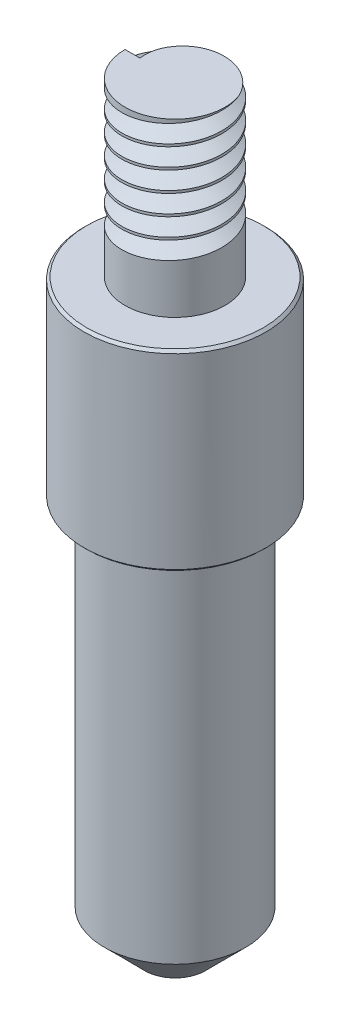
from build123d import *

# Parameters (mm, degrees)
CHAMFER1_SIZE = 0.25
CHAMFER2_SIZE = 0.25


with BuildPart() as part:
    # Sketch1 → Revolve1 (revolve)
    with BuildSketch(Plane.XY, mode=Mode.PRIVATE) as revolve1_sk:
        Polygon((9, 39), (9, 58), (4.95, 58), (4.95, 75), (0, 75), (0, 0), (3, 0), (7, 4), (7, 39), align=None)
    revolve(revolve1_sk.sketch.rotate(Axis((0, 0, 0), (0, 1, 0)), 90), axis=Axis((0, 0, 0), (0, 1, 0)))  # turned: the seam where the file's is

    # Chamfer1
    chamfer1_edges = [part.edges().sort_by_distance(p)[0] for p in [
        (0, 58, 9),
    ]]
    chamfer(chamfer1_edges, length=CHAMFER1_SIZE)

    # Chamfer2
    chamfer2_edges = [part.edges().sort_by_distance(p)[0] for p in [
        (0, 39, 9),
    ]]
    chamfer(chamfer2_edges, length=CHAMFER2_SIZE)

    # Cut-Sweep2: sweep along a curve in space
    with BuildLine() as cut_sweep2_path:
        add(Edge.make_bspline(
            [(-5, 75, 0), (-5, 74.958599466, -0.650318071), (-4.739659358, 74.874876487, -1.965130442), (-3.627578223, 74.750033095, -3.627069319), (-1.963231187, 74.624991132, -4.739795718), (0, 74.500002376, -5.130133783), (1.963231187, 74.374999363, -4.739669148), (3.627578223, 74.250000171, -3.627575599), (4.739659358, 74.124999954, -1.96323189), (5.130170321, 74.000000012, 1.88e-07), (4.739659358, 73.874999997, 1.963231137), (3.627578223, 73.750000001, 3.627578236), (1.963231187, 73.625, 4.739659354), (0, 73.5, 5.130170322), (-1.963231187, 73.375, 4.739659358), (-3.627578223, 73.25, 3.627578223), (-4.739659358, 73.125, 1.963231187), (-5.130170321, 73, 0), (-4.739659358, 72.875, -1.963231187), (-3.627578223, 72.75, -3.627578223), (-1.963231187, 72.625, -4.739659358), (0, 72.5, -5.130170321), (1.963231187, 72.375, -4.739659358), (3.627578223, 72.25, -3.627578223), (4.739659358, 72.125, -1.963231187), (5.130170321, 72, 0), (4.739659358, 71.875, 1.963231187), (3.627578223, 71.75, 3.627578223), (1.963231187, 71.625, 4.739659358), (0, 71.5, 5.130170321), (-1.963231187, 71.375, 4.739659358), (-3.627578223, 71.25, 3.627578223), (-4.739659358, 71.125, 1.963231187), (-5.130170321, 71, 0), (-4.739659358, 70.875, -1.963231187), (-3.627578223, 70.75, -3.627578223), (-1.963231187, 70.625, -4.739659358), (0, 70.5, -5.130170321), (1.963231187, 70.375, -4.739659358), (3.627578223, 70.25, -3.627578223), (4.739659358, 70.125, -1.963231187), (5.130170321, 70, 0), (4.739659358, 69.875, 1.963231187), (3.627578223, 69.75, 3.627578223), (1.963231187, 69.625, 4.739659358), (0, 69.5, 5.130170321), (-1.963231187, 69.375, 4.739659358), (-3.627578223, 69.25, 3.627578223), (-4.739659358, 69.125, 1.963231187), (-5.130170321, 69, 0), (-4.739659358, 68.875, -1.963231187), (-3.627578223, 68.75, -3.627578223), (-1.963231187, 68.625, -4.739659358), (0, 68.5, -5.130170321), (1.963231187, 68.375, -4.739659358), (3.627578223, 68.25, -3.627578223), (4.739659358, 68.125, -1.963231187), (5.130170321, 68, 0), (4.739659358, 67.875, 1.963231187), (3.627578223, 67.75, 3.627578223), (1.963231187, 67.625, 4.739659358), (0, 67.5, 5.130170321), (-1.963231187, 67.375, 4.739659358), (-3.627578223, 67.25, 3.627578223), (-4.739659358, 67.125, 1.963231187), (-5.130170321, 67, 0), (-4.739659358, 66.875, -1.963231187), (-3.627578223, 66.75, -3.627578223), (-1.963231187, 66.625, -4.739659358), (0, 66.5, -5.130170321), (1.963231187, 66.375, -4.739659358), (3.627578223, 66.25, -3.627578223), (4.739659358, 66.125, -1.963231187), (5.130170321, 66, 0), (4.739659358, 65.875, 1.963231187), (3.627578223, 65.75, 3.627578223), (1.963231187, 65.625, 4.739659358), (0, 65.5, 5.130170321), (-1.963231187, 65.375, 4.739659358), (-3.627578223, 65.25, 3.627578223), (-4.739659358, 65.125, 1.963231187), (-5.130170321, 65, 0), (-4.739659358, 64.875, -1.963231187), (-3.627578223, 64.75, -3.627578223), (-1.963231187, 64.625, -4.739659358), (0, 64.5, -5.130170322), (1.963231187, 64.375, -4.739659354), (3.627578223, 64.249999999, -3.627578236), (4.739659358, 64.125000003, -1.963231137), (5.130170321, 63.999999988, -1.88e-07), (4.739659358, 63.875000046, 1.96323189), (3.627578223, 63.749999829, 3.627575599), (1.963231187, 63.625000637, 4.739669148), (0, 63.499997624, 5.130133783), (-1.963231187, 63.375008868, 4.739795718), (-3.627578223, 63.249966905, 3.627069319), (-4.739659358, 63.125123513, 1.965130442), (-5, 63.041400534, 0.650318071), (-5, 63, 0)],
            knots=[0, 0, 0, 0, 0.010416667, 0.020833333, 0.03125, 0.041666667, 0.052083333, 0.0625, 0.072916667, 0.083333333, 0.09375, 0.104166667, 0.114583333, 0.125, 0.135416667, 0.145833333, 0.15625, 0.166666667, 0.177083333, 0.1875, 0.197916667, 0.208333333, 0.21875, 0.229166667, 0.239583333, 0.25, 0.260416667, 0.270833333, 0.28125, 0.291666667, 0.302083333, 0.3125, 0.322916667, 0.333333333, 0.34375, 0.354166667, 0.364583333, 0.375, 0.385416667, 0.395833333, 0.40625, 0.416666667, 0.427083333, 0.4375, 0.447916667, 0.458333333, 0.46875, 0.479166667, 0.489583333, 0.5, 0.510416667, 0.520833333, 0.53125, 0.541666667, 0.552083333, 0.5625, 0.572916667, 0.583333333, 0.59375, 0.604166667, 0.614583333, 0.625, 0.635416667, 0.645833333, 0.65625, 0.666666667, 0.677083333, 0.6875, 0.697916667, 0.708333333, 0.71875, 0.729166667, 0.739583333, 0.75, 0.760416667, 0.770833333, 0.78125, 0.791666667, 0.802083333, 0.8125, 0.822916667, 0.833333333, 0.84375, 0.854166667, 0.864583333, 0.875, 0.885416667, 0.895833333, 0.90625, 0.916666667, 0.927083333, 0.9375, 0.947916667, 0.958333333, 0.96875, 0.979166667, 0.989583333, 1, 1, 1, 1], degree=3))
    # Sketch3 → Cut-Sweep2 (sweep, cut)
    with BuildSketch(Plane(origin=(-5, 75, 0), x_dir=(-1, 0, 0), z_dir=(0, -0.063533362, -0.997979715))):
        Polygon((-1.561869267, -0.020738498), (0.627155903, -1.229235683), (0.579232581, 1.270764317), align=None)
    sweep(path=cut_sweep2_path.line, is_frenet=True, mode=Mode.SUBTRACT)


solid = part.part
